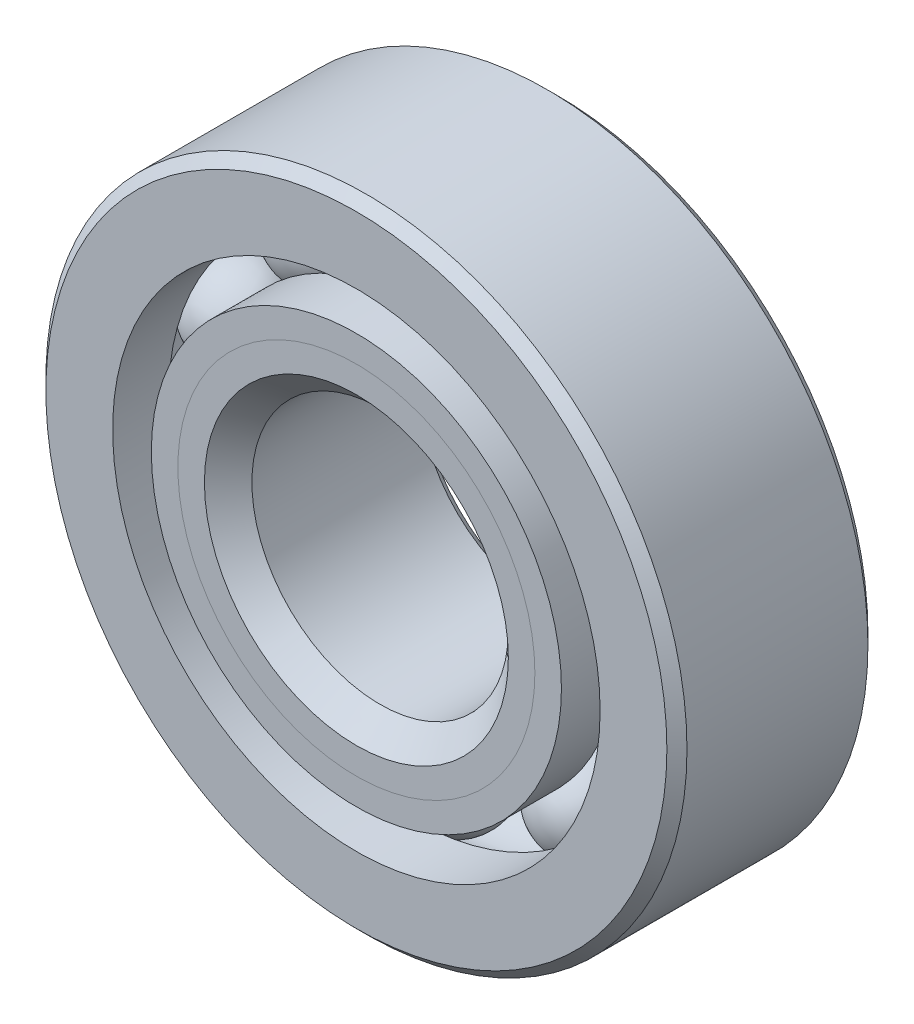
from build123d import *

# Parameters (mm, degrees)
CIRPATTERN1_COUNT = 10


with BuildPart() as part:
    # Sketch1 → Revolve1 (revolve)
    with BuildSketch(Plane(origin=(0, 0, 0), x_dir=(0, 0, -1), z_dir=(1, 0, 0))):
        with BuildLine():
            Line((2.24028, 7.9375), (-2.24028, 7.9375))
            Line((-2.24028, 7.9375), (-2.4892, 7.68858))
            Line((-2.4892, 7.68858), (-2.4892, 6.035221429))
            Line((-2.4892, 6.035221429), (-1.106311111, 6.035221429))
            ThreePointArc((-1.106311111, 6.035221429), (0, 6.76179465), (1.106311111, 6.035221429))
            Line((1.106311111, 6.035221429), (2.4892, 6.035221429))
            Line((2.4892, 6.035221429), (2.4892, 7.68858))
            Line((2.4892, 7.68858), (2.24028, 7.9375))
        make_face()
    revolve(axis=Axis((0, 0, 2.4892), (0, 0, -1)))


with BuildPart() as body_2:
    # Sketch2 → Revolve2 (revolve)
    with BuildSketch(Plane(origin=(0, 0, 0), x_dir=(0, 0, -1), z_dir=(1, 0, 0))):
        with BuildLine():
            Line((-2.4892, 5.077278571), (-1.106311111, 5.077278571))
            ThreePointArc((-1.106311111, 5.077278571), (-0.661784127, 4.548589505), (0, 4.35070535))
            Line((0, 4.35070535), (0, 3.762852675))
            Line((0, 3.762852675), (-1.831987052, 3.762852675))
            Line((-1.831987052, 3.762852675), (-2.4892, 4.420065623))
            Line((-2.4892, 4.420065623), (-2.4892, 5.077278571))
        make_face()
    revolve(axis=Axis((0, 0, 2.4892), (0, 0, -1)))


with BuildPart() as body_3:
    # Sketch3 → Revolve3 (revolve)
    with BuildSketch(Plane(origin=(0, 0, 0), x_dir=(0, 0, -1), z_dir=(1, 0, 0))):
        with BuildLine():
            Line((-2.4892, 4.420065623), (-1.831987052, 3.762852675))
            Line((-1.831987052, 3.762852675), (0, 3.762852675))
            Line((0, 3.762852675), (0, 4.35070535))
            ThreePointArc((0, 4.35070535), (0.661784127, 4.548589505), (1.106311111, 5.077278571))
            Line((1.106311111, 5.077278571), (2.4892, 5.077278571))
            Line((2.4892, 5.077278571), (2.4892, 3.42392))
            Line((2.4892, 3.42392), (2.24028, 3.175))
            Line((2.24028, 3.175), (-1.901347325, 3.175))
            Line((-1.901347325, 3.175), (-2.4892, 3.762852675))
            Line((-2.4892, 3.762852675), (-2.4892, 4.420065623))
        make_face()
    revolve(axis=Axis((0, 0, 2.4892), (0, 0, -1)))


with BuildPart() as body_4:
    # Sketch4 → Revolve4 (revolve)
    with BuildSketch(Plane(origin=(0, 0, 0), x_dir=(0, 0, -1), z_dir=(1, 0, 0))):
        with BuildLine():
            Line((-1.20554465, 5.55625), (1.20554465, 5.55625))
            ThreePointArc((1.20554465, 5.55625), (0, 6.76179465), (-1.20554465, 5.55625))
        make_face()
    revolve(axis=Axis((0, 5.55625, 1.20554465), (0, 0, -1)))


with BuildPart() as cirpattern1_1:
    # CirPattern1: pattern copy
    add(body_4.part.rotate(Axis((0, 0, -2.4892), (0, 0, 1)), 1 * 360 / CIRPATTERN1_COUNT))


with BuildPart() as cirpattern1_2:
    # CirPattern1: pattern copy
    add(body_4.part.rotate(Axis((0, 0, -2.4892), (0, 0, 1)), 2 * 360 / CIRPATTERN1_COUNT))


with BuildPart() as cirpattern1_3:
    # CirPattern1: pattern copy
    add(body_4.part.rotate(Axis((0, 0, -2.4892), (0, 0, 1)), 3 * 360 / CIRPATTERN1_COUNT))


with BuildPart() as cirpattern1_4:
    # CirPattern1: pattern copy
    add(body_4.part.rotate(Axis((0, 0, -2.4892), (0, 0, 1)), 4 * 360 / CIRPATTERN1_COUNT))


with BuildPart() as cirpattern1_5:
    # CirPattern1: pattern copy
    add(body_4.part.rotate(Axis((0, 0, -2.4892), (0, 0, 1)), 5 * 360 / CIRPATTERN1_COUNT))


with BuildPart() as cirpattern1_6:
    # CirPattern1: pattern copy
    add(body_4.part.rotate(Axis((0, 0, -2.4892), (0, 0, 1)), 6 * 360 / CIRPATTERN1_COUNT))


with BuildPart() as cirpattern1_7:
    # CirPattern1: pattern copy
    add(body_4.part.rotate(Axis((0, 0, -2.4892), (0, 0, 1)), 7 * 360 / CIRPATTERN1_COUNT))


with BuildPart() as cirpattern1_8:
    # CirPattern1: pattern copy
    add(body_4.part.rotate(Axis((0, 0, -2.4892), (0, 0, 1)), 8 * 360 / CIRPATTERN1_COUNT))


with BuildPart() as cirpattern1_9:
    # CirPattern1: pattern copy
    add(body_4.part.rotate(Axis((0, 0, -2.4892), (0, 0, 1)), 9 * 360 / CIRPATTERN1_COUNT))


solid = Compound([part.part, body_2.part, body_3.part, body_4.part, cirpattern1_1.part, cirpattern1_2.part, cirpattern1_3.part, cirpattern1_4.part, cirpattern1_5.part, cirpattern1_6.part, cirpattern1_7.part, cirpattern1_8.part, cirpattern1_9.part])
